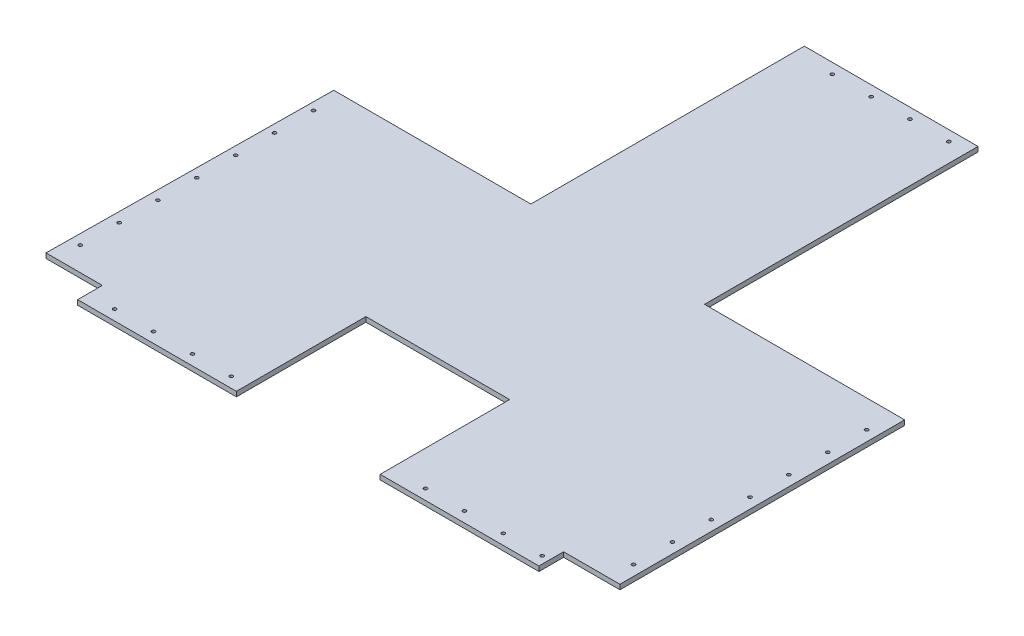
from build123d import *

# Parameters (mm, degrees)
BOSS_EXTRUDE1_DEPTH = 5
SKETCH2_R           = 1.75
CUT_EXTRUDE1_DEPTH  = 6


with BuildPart() as part:
    # Sketch1 → Boss-Extrude1 (new body)
    with BuildSketch(Plane(origin=(0, 329.925662842, 0), x_dir=(1, 0, 0), z_dir=(0, 1, 0))):
        Polygon((180.899872759, -210.782719675), (180.899872759, 70.717280325), (359.699872759, 70.717280325), (359.699872759, -210.782719675), (565.699872759, -210.782719675), (565.699872759, -503.882719675), (507.724872759, -503.882719675), (507.724872759, -529.282719675), (344.299872759, -529.282719675), (344.299872759, -396.017719675), (196.299872759, -396.017719675), (196.299872759, -529.282719675), (32.874872759, -529.282719675), (32.874872759, -503.882719675), (-25.100127241, -503.882719675), (-21.925127241, -210.782719675), align=None)
    extrude(amount=BOSS_EXTRUDE1_DEPTH)

    # Sketch2 → Cut-Extrude1 (cut, through all)
    with BuildSketch(Plane.XZ.offset(-329.925662842)):
        with Locations((60.299872759, 518.607719675)):
            Circle(SKETCH2_R)
        with Locations((380.299872759, 518.607719675)):
            Circle(SKETCH2_R)
        with Locations((220.299872759, -60.042280325)):
            Circle(SKETCH2_R)
        with Locations((100.299872759, 518.607719675)):
            Circle(SKETCH2_R)
        with Locations((420.299872759, 518.607719675)):
            Circle(SKETCH2_R)
        with Locations((260.299872759, -60.042280325)):
            Circle(SKETCH2_R)
        with Locations((140.299872759, 518.607719675)):
            Circle(SKETCH2_R)
        with Locations((460.299872759, 518.607719675)):
            Circle(SKETCH2_R)
        with Locations((300.299872759, -60.042280325)):
            Circle(SKETCH2_R)
        with Locations((180.299872759, 518.607719675)):
            Circle(SKETCH2_R)
        with Locations((500.299872759, 518.607719675)):
            Circle(SKETCH2_R)
        with Locations((340.299872759, -60.042280325)):
            Circle(SKETCH2_R)
        with Locations((-14.425127241, 239.282719675)):
            Circle(SKETCH2_R)
        with Locations((555.024872759, 239.282719675)):
            Circle(SKETCH2_R)
        with Locations((-14.425127241, 279.282719675)):
            Circle(SKETCH2_R)
        with Locations((555.024872759, 279.282719675)):
            Circle(SKETCH2_R)
        with Locations((-14.425127241, 319.282719675)):
            Circle(SKETCH2_R)
        with Locations((555.024872759, 319.282719675)):
            Circle(SKETCH2_R)
        with Locations((-14.425127241, 359.282719675)):
            Circle(SKETCH2_R)
        with Locations((555.024872759, 359.282719675)):
            Circle(SKETCH2_R)
        with Locations((-14.425127241, 399.282719675)):
            Circle(SKETCH2_R)
        with Locations((555.024872759, 399.282719675)):
            Circle(SKETCH2_R)
        with Locations((-14.425127241, 439.282719675)):
            Circle(SKETCH2_R)
        with Locations((555.024872759, 439.282719675)):
            Circle(SKETCH2_R)
        with Locations((-14.425127241, 479.282719675)):
            Circle(SKETCH2_R)
        with Locations((555.024872759, 479.282719675)):
            Circle(SKETCH2_R)
    extrude(amount=-CUT_EXTRUDE1_DEPTH, mode=Mode.SUBTRACT)


solid = part.part
